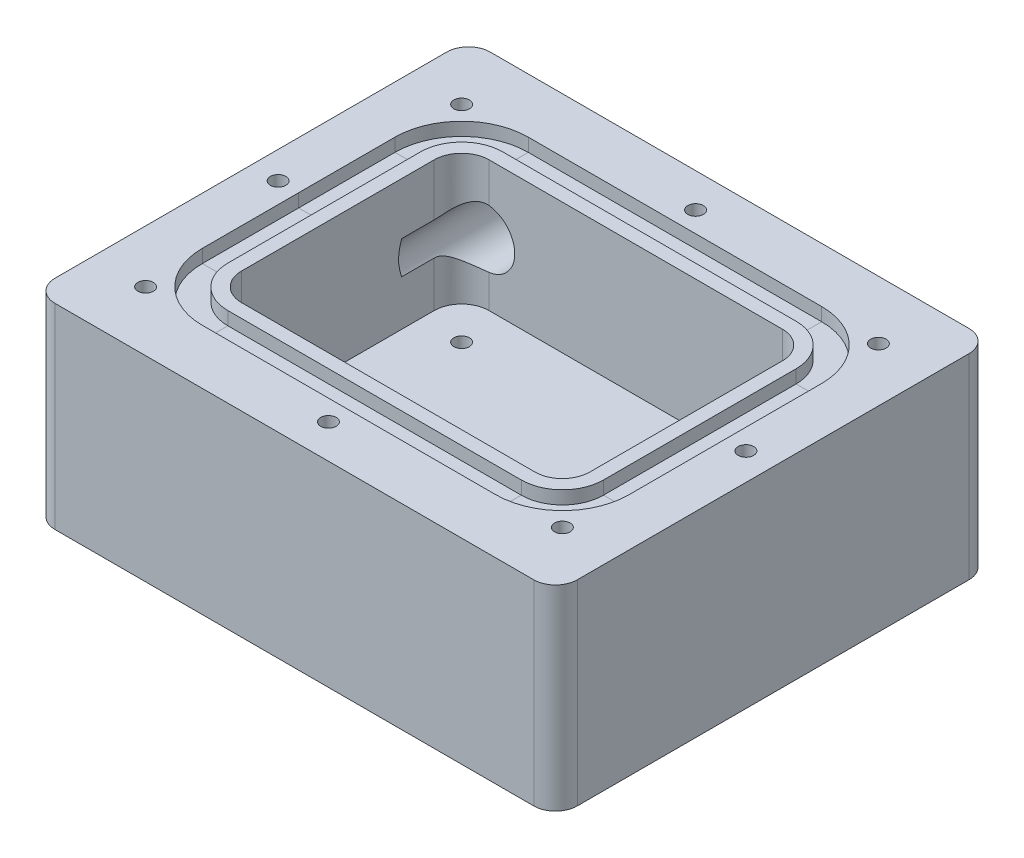
from build123d import *

# Parameters (mm, degrees)
SKETCH1_W                  = 76.2
SKETCH1_H                  = 63.5
BOSS_EXTRUDE1_DEPTH        = 14.2875
SKETCH2_W                  = 50.8
SKETCH2_H                  = 36.1
CUT_EXTRUDE1_DEPTH         = 19.05
M10X1_5_TAPPED_HOLE1_D     = 8.5
M10X1_5_TAPPED_HOLE1_DEPTH = 22.446342369
M10X1_5_TAPPED_HOLE1_TIP   = 2.553657631
SKETCH16_W                 = 3.724215622
SKETCH16_H                 = 1.92405
FILLET2_R                  = 3.175
F_4_40_TAPPED_HOLE2_D      = 2.2606
F_4_40_TAPPED_HOLE2_DEPTH  = 6.920847242
F_4_40_TAPPED_HOLE2_TIP    = 0.679152758
FILLET3_R                  = 4
F_4_40_TAPPED_HOLE3_D      = 2.2606
F_4_40_TAPPED_HOLE3_DEPTH  = 4.320847242
F_4_40_TAPPED_HOLE3_TIP    = 0.679152758
F_8_32_TAPPED_HOLE1_D      = 3.4544
F_8_32_TAPPED_HOLE1_DEPTH  = 9.672193539
F_8_32_TAPPED_HOLE1_TIP    = 1.037806461


with BuildPart() as part:
    # Sketch1 → Boss-Extrude1 (new body, symmetric)
    with BuildSketch(Plane(origin=(0, 0, 0), x_dir=(1, 0, 0), z_dir=(0, 1, 0))):
        Rectangle(SKETCH1_W, SKETCH1_H)
    extrude(amount=BOSS_EXTRUDE1_DEPTH, both=True)

    # Sketch2 → Cut-Extrude1 (cut)
    with BuildSketch(Plane(origin=(0, 14.2875, 0), x_dir=(1, 0, 0), z_dir=(0, 1, 0))):
        Rectangle(SKETCH2_W, SKETCH2_H)
    extrude(amount=-CUT_EXTRUDE1_DEPTH, mode=Mode.SUBTRACT)

    # M10x1.5 Tapped Hole1
    with Locations(Plane(origin=(-21.9, 4.2875, -31.75), x_dir=(-1, 0, 0), z_dir=(0, 0, -1))):
        with Locations((0, 0)):
            Hole(M10X1_5_TAPPED_HOLE1_D / 2, depth=M10X1_5_TAPPED_HOLE1_DEPTH)
            with Locations((0, 0, -(M10X1_5_TAPPED_HOLE1_DEPTH + M10X1_5_TAPPED_HOLE1_TIP / 2))):  # 118° drill point
                Cone(0, M10X1_5_TAPPED_HOLE1_D / 2, M10X1_5_TAPPED_HOLE1_TIP, mode=Mode.SUBTRACT)

    # Cut-Sweep1: sweep along a path in Sketch14
    with BuildLine(Plane(origin=(0, 14.2875, 0), x_dir=(1, 0, 0), z_dir=(0, 1, 0))) as cut_sweep1_path:
        Line((-21.4, 20.05), (21.4, 20.05))
        ThreePointArc((21.4, 20.05), (25.642640687, 18.292640687), (27.4, 14.05))
        Line((27.4, 14.05), (27.4, -14.05))
        ThreePointArc((27.4, -14.05), (25.642640687, -18.292640687), (21.4, -20.05))
        Line((21.4, -20.05), (-21.4, -20.05))
        ThreePointArc((-21.4, -20.05), (-25.642640687, -18.292640687), (-27.4, -14.05))
        Line((-27.4, -14.05), (-27.4, 14.05))
        ThreePointArc((-27.4, 14.05), (-25.642640687, 18.292640687), (-21.4, 20.05))
    # Sketch16 → Cut-Sweep1 (sweep, cut)
    with BuildSketch(Plane.XY):
        with Locations((-29.262107811, 13.325475)):
            Rectangle(SKETCH16_W, SKETCH16_H)
    sweep(path=cut_sweep1_path.line, mode=Mode.SUBTRACT)

    # Fillet2
    fillet2_edges = [part.edges().sort_by_distance(p)[0] for p in [
        (38.1, 0, 31.75),
        (-38.1, 0, 31.75),
        (-38.1, 0, -31.75),
        (38.1, 0, -31.75),
    ]]
    fillet(fillet2_edges, radius=FILLET2_R)

    # #4-40 Tapped Hole2
    with Locations(Plane(origin=(0, 14.2875, 0), x_dir=(1, 0, 0), z_dir=(0, 1, 0))):
        with Locations((34.124215622, 0), (30.228658441, 23.222452534), (-30.397379151, 23.047379151), (30.397379151, -23.047379151), (-30.397379151, -23.047379151), (0, -26.774215622), (-34.124215622, 0), (0.004913792, 26.774215622)):
            Hole(F_4_40_TAPPED_HOLE2_D / 2, depth=F_4_40_TAPPED_HOLE2_DEPTH)
            with Locations((0, 0, -(F_4_40_TAPPED_HOLE2_DEPTH + F_4_40_TAPPED_HOLE2_TIP / 2))):  # 118° drill point
                Cone(0, F_4_40_TAPPED_HOLE2_D / 2, F_4_40_TAPPED_HOLE2_TIP, mode=Mode.SUBTRACT)

    # Fillet3
    fillet3_edges = [part.edges().sort_by_distance(p)[0] for p in [
        (25.4, 4.7625, -18.05),
        (25.4, 4.7625, 18.05),
        (-25.4, 4.7625, 18.05),
        (-25.4, -1.442956345, -18.05),
        (-25.4, 10.492956345, -18.05),
    ]]
    fillet(fillet3_edges, radius=FILLET3_R)

    # #4-40 Tapped Hole3
    with Locations(Plane(origin=(19.4, -4.7625, -12.05), x_dir=(0, 0, 1), z_dir=(0, 1, 0))):
        with Locations((0, 0), (24.1, 0), (24.1, -38.8), (0, -38.8)):
            Hole(F_4_40_TAPPED_HOLE3_D / 2, depth=F_4_40_TAPPED_HOLE3_DEPTH)
            with Locations((0, 0, -(F_4_40_TAPPED_HOLE3_DEPTH + F_4_40_TAPPED_HOLE3_TIP / 2))):  # 118° drill point
                Cone(0, F_4_40_TAPPED_HOLE3_D / 2, F_4_40_TAPPED_HOLE3_TIP, mode=Mode.SUBTRACT)

    # #8-32 Tapped Hole1
    with Locations(Plane.XZ.offset(14.2875)):
        with Locations((32.75, -12.7), (-32.75, 12.7), (-32.75, -12.7), (32.75, 12.7)):
            Hole(F_8_32_TAPPED_HOLE1_D / 2, depth=F_8_32_TAPPED_HOLE1_DEPTH)
            with Locations((0, 0, -(F_8_32_TAPPED_HOLE1_DEPTH + F_8_32_TAPPED_HOLE1_TIP / 2))):  # 118° drill point
                Cone(0, F_8_32_TAPPED_HOLE1_D / 2, F_8_32_TAPPED_HOLE1_TIP, mode=Mode.SUBTRACT)


solid = part.part
